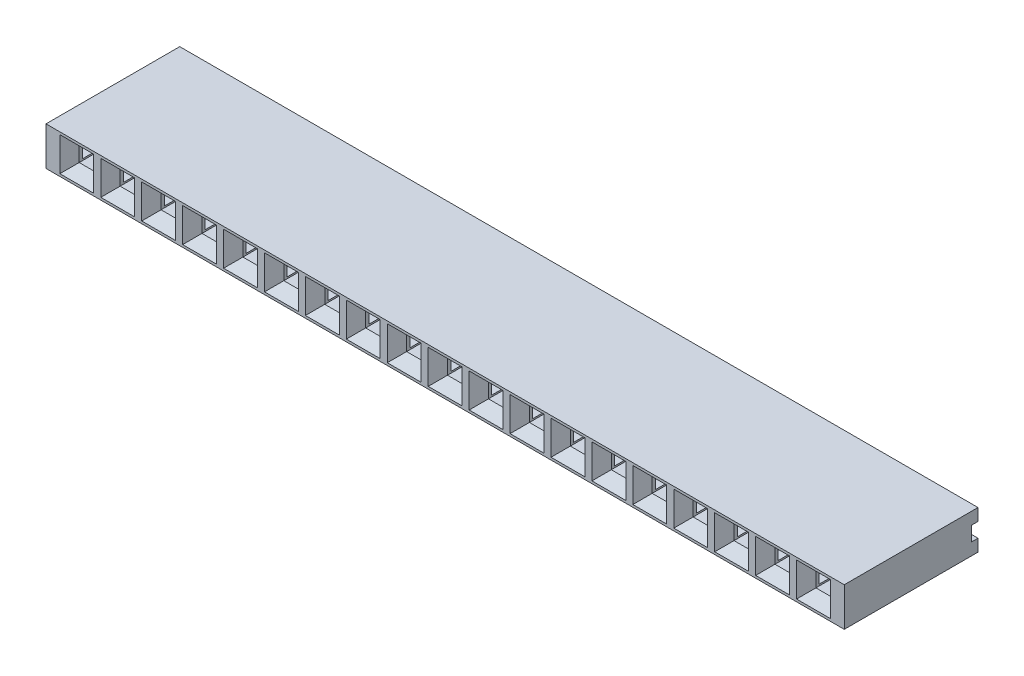
from build123d import *

# Parameters (mm, degrees)
SKETCH_233_W              = 2.54
SKETCH_233_H              = 2.4
EXTRUDE_710_DEPTH         = 6.7
EXTRUDE_710_DEPTH_BACK    = 0.4
SKETCH_764_W              = 2.54
SKETCH_764_H              = 0.75
EXTRUDE_1143_DEPTH        = 0.4
SKETCH_1197_W             = 2.54
SKETCH_1197_H             = 2.4
SKETCH_1197_W_2           = 0.9
SKETCH_1197_H_2           = 0.9
EXTRUDE_1482_DEPTH        = 0.8
CHAMFER_1543_SIZE         = 0.6
PATTERN_LINEAR_1669_COUNT = 19
PATTERN_LINEAR_1669_PITCH = 2.54
EXTRUDE_1_DEPTH           = 0.64
EXTRUDE_START             = -48.9
EXTRUDE_2_DEPTH           = 0.64


with BuildPart() as part:
    # Sketch 233 → Extrude 710 (new body, two sides)
    with BuildSketch(Plane.XY) as extrude_710_sk:
        Rectangle(SKETCH_233_W, SKETCH_233_H)
        Polygon((-1, 0.35), (-0.45, 0.35), (-0.45, 0.45), (0.45, 0.45), (0.45, 0.35), (1, 0.35), (1, -0.35), (0.45, -0.35), (0.45, -0.45), (-0.45, -0.45), (-0.45, -0.35), (-1, -0.35), align=None, mode=Mode.SUBTRACT)
    extrude(amount=EXTRUDE_710_DEPTH)
    extrude(extrude_710_sk.sketch, amount=-EXTRUDE_710_DEPTH_BACK)

    # Sketch 764 → Extrude 1143 (add)
    with BuildSketch(Plane(origin=(0, 0, -0.4), x_dir=(-1, 0, 0), z_dir=(0, 0, -1))):
        with Locations((0, -0.825)):
            Rectangle(SKETCH_764_W, SKETCH_764_H)
        with Locations((0, 0.825)):
            Rectangle(SKETCH_764_W, SKETCH_764_H)
    extrude(amount=EXTRUDE_1143_DEPTH)

    # Sketch 1197 → Extrude 1482 (add)
    with BuildSketch(Plane.XY.offset(6.7)):
        Rectangle(SKETCH_1197_W, SKETCH_1197_H)
        Rectangle(SKETCH_1197_W_2, SKETCH_1197_H_2, mode=Mode.SUBTRACT)
    extrude(amount=EXTRUDE_1482_DEPTH)

    # Chamfer 1543
    chamfer_1543_edges = [part.edges().sort_by_distance(p)[0] for p in [
        (0.45, 0, 7.5),
        (0, 0.45, 7.5),
        (-0.45, 0, 7.5),
        (0, -0.45, 7.5),
    ]]
    chamfer(chamfer_1543_edges, length=CHAMFER_1543_SIZE)


with BuildPart() as pattern_linear_1669_1:
    # Pattern Linear 1669: pattern copy
    add(part.part.moved(Location(Vector(-1, 0, 0) * (1 * PATTERN_LINEAR_1669_PITCH))))


with BuildPart() as pattern_linear_1669_2:
    # Pattern Linear 1669: pattern copy
    add(part.part.moved(Location(Vector(-1, 0, 0) * (2 * PATTERN_LINEAR_1669_PITCH))))


with BuildPart() as pattern_linear_1669_3:
    # Pattern Linear 1669: pattern copy
    add(part.part.moved(Location(Vector(-1, 0, 0) * (3 * PATTERN_LINEAR_1669_PITCH))))


with BuildPart() as pattern_linear_1669_4:
    # Pattern Linear 1669: pattern copy
    add(part.part.moved(Location(Vector(-1, 0, 0) * (4 * PATTERN_LINEAR_1669_PITCH))))


with BuildPart() as pattern_linear_1669_5:
    # Pattern Linear 1669: pattern copy
    add(part.part.moved(Location(Vector(-1, 0, 0) * (5 * PATTERN_LINEAR_1669_PITCH))))


with BuildPart() as pattern_linear_1669_6:
    # Pattern Linear 1669: pattern copy
    add(part.part.moved(Location(Vector(-1, 0, 0) * (6 * PATTERN_LINEAR_1669_PITCH))))


with BuildPart() as pattern_linear_1669_7:
    # Pattern Linear 1669: pattern copy
    add(part.part.moved(Location(Vector(-1, 0, 0) * (7 * PATTERN_LINEAR_1669_PITCH))))


with BuildPart() as pattern_linear_1669_8:
    # Pattern Linear 1669: pattern copy
    add(part.part.moved(Location(Vector(-1, 0, 0) * (8 * PATTERN_LINEAR_1669_PITCH))))


with BuildPart() as pattern_linear_1669_9:
    # Pattern Linear 1669: pattern copy
    add(part.part.moved(Location(Vector(-1, 0, 0) * (9 * PATTERN_LINEAR_1669_PITCH))))


with BuildPart() as pattern_linear_1669_10:
    # Pattern Linear 1669: pattern copy
    add(part.part.moved(Location(Vector(-1, 0, 0) * (10 * PATTERN_LINEAR_1669_PITCH))))


with BuildPart() as pattern_linear_1669_11:
    # Pattern Linear 1669: pattern copy
    add(part.part.moved(Location(Vector(-1, 0, 0) * (11 * PATTERN_LINEAR_1669_PITCH))))


with BuildPart() as pattern_linear_1669_12:
    # Pattern Linear 1669: pattern copy
    add(part.part.moved(Location(Vector(-1, 0, 0) * (12 * PATTERN_LINEAR_1669_PITCH))))


with BuildPart() as pattern_linear_1669_13:
    # Pattern Linear 1669: pattern copy
    add(part.part.moved(Location(Vector(-1, 0, 0) * (13 * PATTERN_LINEAR_1669_PITCH))))


with BuildPart() as pattern_linear_1669_14:
    # Pattern Linear 1669: pattern copy
    add(part.part.moved(Location(Vector(-1, 0, 0) * (14 * PATTERN_LINEAR_1669_PITCH))))


with BuildPart() as pattern_linear_1669_15:
    # Pattern Linear 1669: pattern copy
    add(part.part.moved(Location(Vector(-1, 0, 0) * (15 * PATTERN_LINEAR_1669_PITCH))))


with BuildPart() as pattern_linear_1669_16:
    # Pattern Linear 1669: pattern copy
    add(part.part.moved(Location(Vector(-1, 0, 0) * (16 * PATTERN_LINEAR_1669_PITCH))))


with BuildPart() as pattern_linear_1669_17:
    # Pattern Linear 1669: pattern copy
    add(part.part.moved(Location(Vector(-1, 0, 0) * (17 * PATTERN_LINEAR_1669_PITCH))))


with BuildPart() as pattern_linear_1669_18:
    # Pattern Linear 1669: pattern copy
    add(part.part.moved(Location(Vector(-1, 0, 0) * (18 * PATTERN_LINEAR_1669_PITCH))))


with BuildPart() as part_1:
    add(part.part)

    # Combine 1766: union Pattern Linear 1669_17, Pattern Linear 1669_16, Pattern Linear 1669_15, Pattern Linear 1669_14, Pattern Linear 1669_13, Pattern Linear 1669_12, Pattern Linear 1669_11, Pattern Linear 1669_10, Pattern Linear 1669_9, Pattern Linear 1669_8, Pattern Linear 1669_7, Pattern Linear 1669_6, Pattern Linear 1669_5, Pattern Linear 1669_4, Pattern Linear 1669_3, Pattern Linear 1669_2, Pattern Linear 1669_1, Pattern Linear 1669_18
    add(pattern_linear_1669_17.part)
    add(pattern_linear_1669_16.part)
    add(pattern_linear_1669_15.part)
    add(pattern_linear_1669_14.part)
    add(pattern_linear_1669_13.part)
    add(pattern_linear_1669_12.part)
    add(pattern_linear_1669_11.part)
    add(pattern_linear_1669_10.part)
    add(pattern_linear_1669_9.part)
    add(pattern_linear_1669_8.part)
    add(pattern_linear_1669_7.part)
    add(pattern_linear_1669_6.part)
    add(pattern_linear_1669_5.part)
    add(pattern_linear_1669_4.part)
    add(pattern_linear_1669_3.part)
    add(pattern_linear_1669_2.part)
    add(pattern_linear_1669_1.part)
    add(pattern_linear_1669_18.part)

    # Sketch 2570 → Бобышка-БоковаяНакладка1 (add)
    with BuildSketch(Plane(origin=(1.27, 0, 0), x_dir=(0, 0, -1), z_dir=(1, 0, 0))):
        Polygon((0.8, 1.2), (0.8, 0.45), (0.4, 0.45), (0.4, -0.45), (0.8, -0.45), (0.8, -1.2), (-7.5, -1.2), (-7.5, 1.2), align=None)
    extrude(amount=EXTRUDE_1_DEPTH)

    # Эскиз-БоковаяНакладка<2> → Бобышка-БоковаяНакладка2 (add)
    with BuildSketch(Plane(origin=(1.27, 0, 0), x_dir=(0, 0, -1), z_dir=(1, 0, 0)).offset(EXTRUDE_START)):
        Polygon((0.8, 1.2), (0.8, 0.45), (0.4, 0.45), (0.4, -0.45), (0.8, -0.45), (0.8, -1.2), (-7.5, -1.2), (-7.5, 1.2), align=None)
    extrude(amount=EXTRUDE_2_DEPTH)


solid = part_1.part
